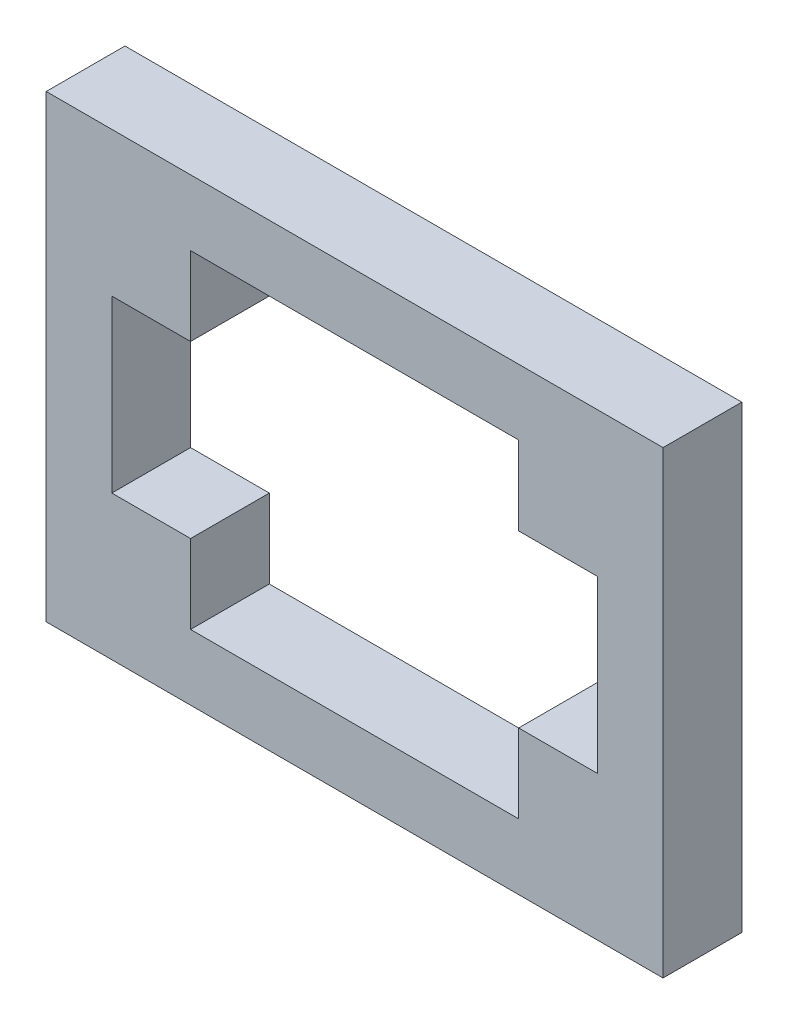
from build123d import *

# Parameters (mm, degrees)
ESBO_O1_W                = 47
ESBO_O1_H                = 35
RESSALTO_EXTRUS_O1_DEPTH = 6


with BuildPart() as part:
    # Esboço1 → Ressalto-extrusão1 (new body)
    with BuildSketch(Plane.XY):
        with Locations((23.5, 17.5)):
            Rectangle(ESBO_O1_W, ESBO_O1_H)
        Polygon((11, 30), (36, 30), (36, 24), (42, 24), (42, 11), (36, 11), (36, 5), (11, 5), (11, 11), (5, 11), (5, 24), (11, 24), align=None, mode=Mode.SUBTRACT)
    extrude(amount=RESSALTO_EXTRUS_O1_DEPTH)


solid = part.part
